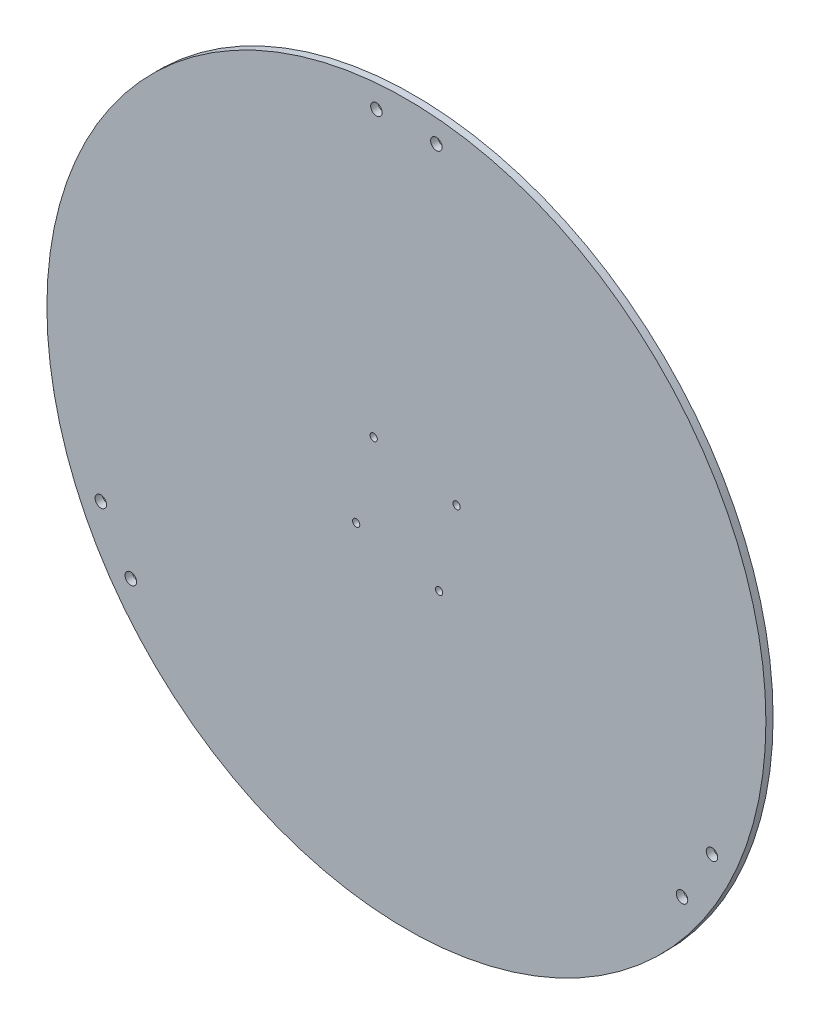
from build123d import *

# Parameters (mm, degrees)
SKETCH1_R                       = 150
SKETCH1_R_2                     = 2.4
BOSS_EXTRUDE2_DEPTH             = 3
F_3_0MM_DOWEL_HOLE2_D           = 3
F_3_0MM_DOWEL_HOLE2_CSINK_D     = 3.05
F_3_0MM_DOWEL_HOLE2_CSINK_ANGLE = 90


with BuildPart() as part:
    # Sketch1 → Boss-Extrude2 (new body)
    with BuildSketch(Plane.XY):
        Circle(SKETCH1_R)
        with Locations((12.5, 140)):
            Circle(SKETCH1_R_2, mode=Mode.SUBTRACT)
        with Locations((-12.5, 140)):
            Circle(SKETCH1_R_2, mode=Mode.SUBTRACT)
        with Locations((127.49355653, -59.174682453)):
            Circle(SKETCH1_R_2, mode=Mode.SUBTRACT)
        with Locations((114.99355653, -80.825317547)):
            Circle(SKETCH1_R_2, mode=Mode.SUBTRACT)
        with Locations((-114.99355653, -80.825317547)):
            Circle(SKETCH1_R_2, mode=Mode.SUBTRACT)
        with Locations((-127.49355653, -59.174682453)):
            Circle(SKETCH1_R_2, mode=Mode.SUBTRACT)
    extrude(amount=BOSS_EXTRUDE2_DEPTH)

    # Ø3.0mm Dowel Hole2 (through all)
    with Locations(Plane(origin=(0, 0, 0), x_dir=(-1, 0, 0), z_dir=(0, 0, -1))):
        with Locations((-20.948618644, 13.643876902), (13.643876902, 20.948618644), (20.948618644, -13.643876902), (-13.643876902, -20.948618644)):
            CounterSinkHole(F_3_0MM_DOWEL_HOLE2_D / 2, F_3_0MM_DOWEL_HOLE2_CSINK_D / 2, counter_sink_angle=F_3_0MM_DOWEL_HOLE2_CSINK_ANGLE)


solid = part.part
